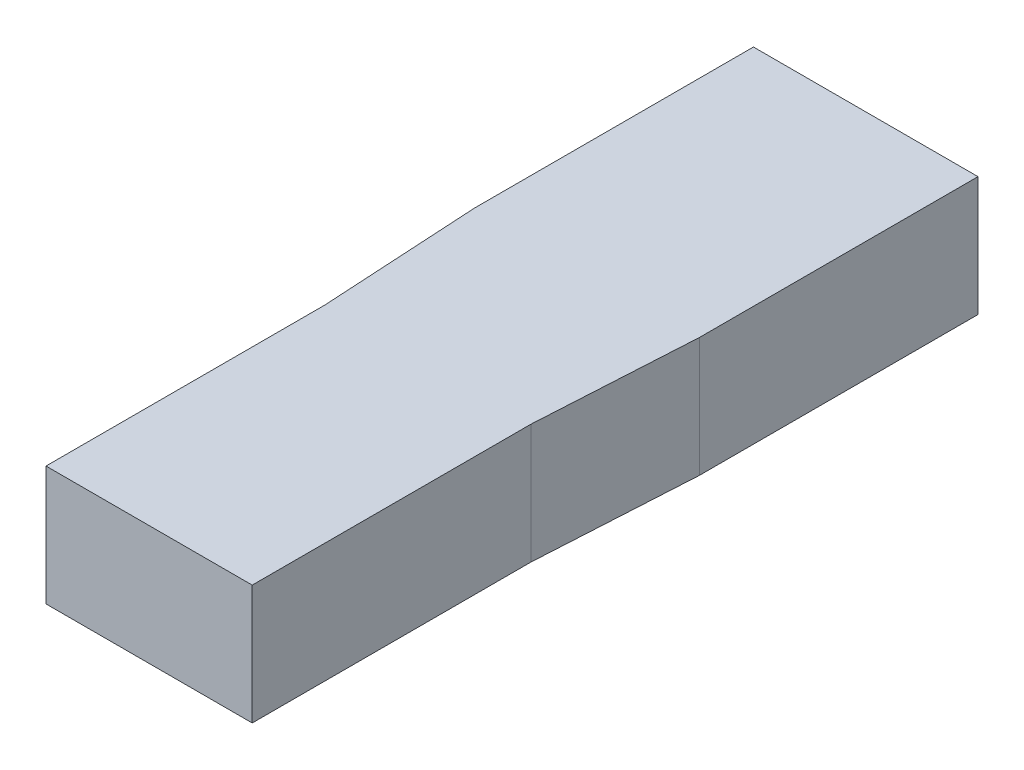
from build123d import *

# Parameters (mm, degrees)
SKETCH1_W           = 5.64
SKETCH1_H           = 18
BOSS_EXTRUDE1_DEPTH = 3
CUT_EXTRUDE1_START  = -4
CUT_EXTRUDE1_DEPTH  = 5


with BuildPart() as part:
    # Sketch1 → Boss-Extrude1 (new body)
    with BuildSketch(Plane(origin=(0, 0, 0), x_dir=(1, 0, 0), z_dir=(0, 1, 0))):
        Rectangle(SKETCH1_W, SKETCH1_H)
    extrude(amount=BOSS_EXTRUDE1_DEPTH)

    # Sketch2 → Cut-Extrude1 (cut)
    with BuildSketch(Plane(origin=(0, 3, 0), x_dir=(1, 0, 0), z_dir=(0, 1, 0)).offset(CUT_EXTRUDE1_START)):
        Polygon((-2.59, -9), (-2.59, -2), (-2.82, 2), (-2.82, -9), align=None)
    cut_extrude1 = extrude(amount=CUT_EXTRUDE1_DEPTH, mode=Mode.SUBTRACT)

    # Mirror1: Cut-Extrude1 across plane
    add(cut_extrude1.mirror(Plane(origin=(0, 0, 0), x_dir=(0, 0, 1), z_dir=(1, 0, 0))), mode=Mode.SUBTRACT)


solid = part.part
